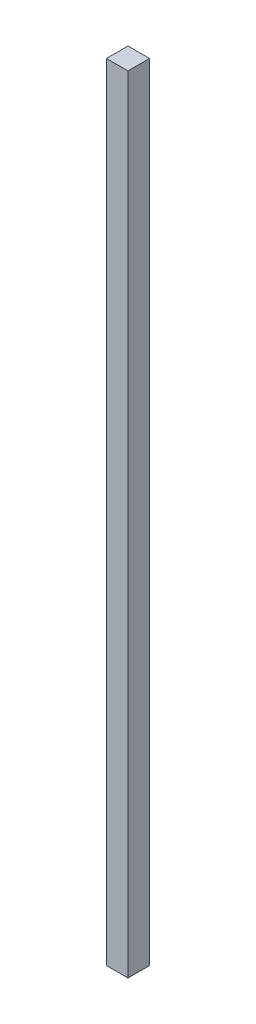
from build123d import *

# Parameters (mm, degrees)
SKETCH1_W           = 76.2
SKETCH1_H           = 76.2
BOSS_EXTRUDE1_DEPTH = 2775.06872708


with BuildPart() as part:
    # Sketch1 → Boss-Extrude1 (new body)
    with BuildSketch(Plane(origin=(0, 0, 0), x_dir=(1, 0, 0), z_dir=(0, 1, 0))):
        Rectangle(SKETCH1_W, SKETCH1_H)
    extrude(amount=BOSS_EXTRUDE1_DEPTH)


solid = part.part
